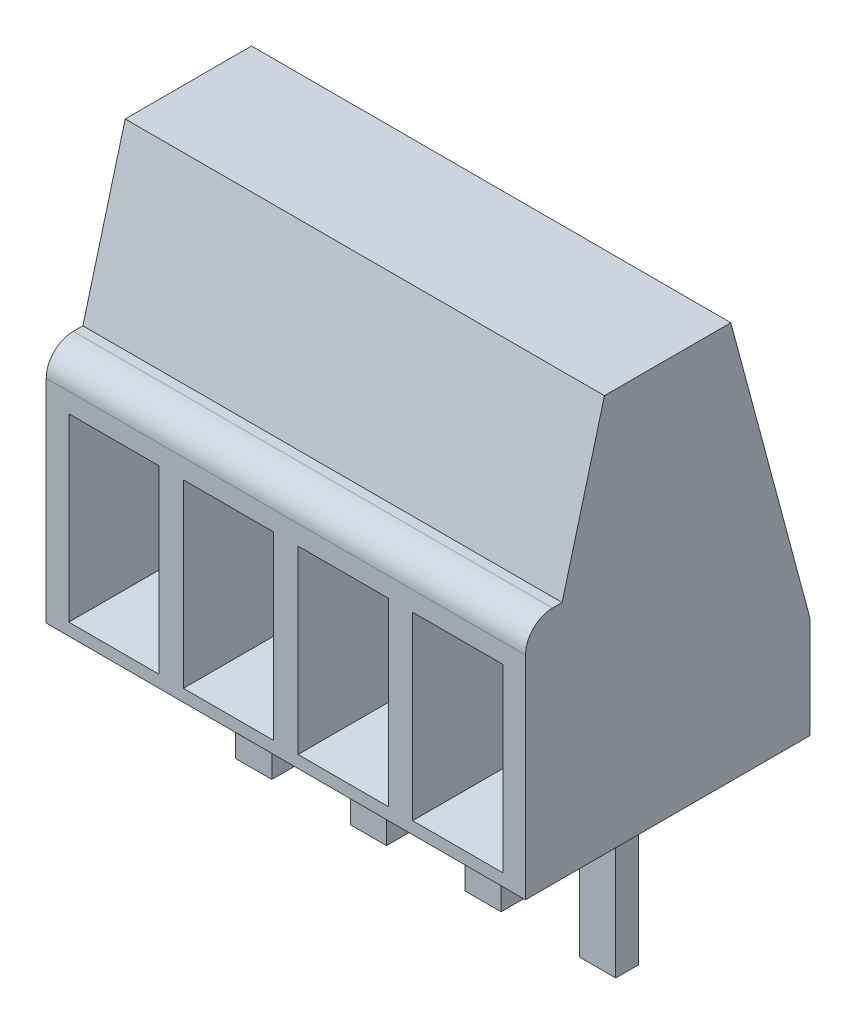
from build123d import *

# Parameters (mm, degrees)
SKETCH1_W           = 10.62
SKETCH1_H           = 6.3
BOSS_EXTRUDE1_DEPTH = 8.8
SKETCH2_W           = 0.8
SKETCH2_H           = 0.5
BOSS_EXTRUDE2_DEPTH = 3.6
CUT_EXTRUDE1_REACH  = 12.62
SKETCH4_W           = 2
SKETCH4_H           = 4
CUT_EXTRUDE2_DEPTH  = 3.15
CUT_EXTRUDE2_TAPER  = 10


with BuildPart() as part:
    # Sketch1 → Boss-Extrude1 (new body)
    with BuildSketch(Plane(origin=(0, 0, 0), x_dir=(1, 0, 0), z_dir=(0, 1, 0))):
        Rectangle(SKETCH1_W, SKETCH1_H)
    extrude(amount=BOSS_EXTRUDE1_DEPTH)

    # Sketch2 → Boss-Extrude2 (add)
    with BuildSketch(Plane(origin=(0, 0, 0), x_dir=(1, 0, 0), z_dir=(0, 1, 0))):
        with Locations((1.27, 0.2)):
            Rectangle(SKETCH2_W, SKETCH2_H)
        with Locations((3.81, 0.2)):
            Rectangle(SKETCH2_W, SKETCH2_H)
        with Locations((-1.27, 0.2)):
            Rectangle(SKETCH2_W, SKETCH2_H)
        with Locations((-3.81, 0.2)):
            Rectangle(SKETCH2_W, SKETCH2_H)
    extrude(amount=-BOSS_EXTRUDE2_DEPTH)

    # Sketch3 → Cut-Extrude1 (cut, up to next)
    with BuildSketch(Plane(origin=(5.31, 0, 0), x_dir=(0, 0, -1), z_dir=(1, 0, 0)), mode=Mode.PRIVATE) as cut_extrude1_sk1:
        with BuildLine():
            ThreePointArc((-3.15, 4.7), (-2.974264069, 5.124264069), (-2.55, 5.3))
            Line((-2.55, 5.3), (-2.337822174, 5.3))
            Line((-2.337822174, 5.3), (-1.4, 8.8))
            Line((-1.4, 8.8), (-3.15, 8.8))
            Line((-3.15, 8.8), (-3.15, 4.7))
        make_face()
    cut_extrude1_tool1 = extrude(cut_extrude1_sk1.sketch, amount=-CUT_EXTRUDE1_REACH, mode=Mode.PRIVATE) & part.part
    add(cut_extrude1_tool1.solids().sort_by_distance((5.31, 7.227986, 2.489914))[0], mode=Mode.SUBTRACT)
    # Sketch3 → Cut-Extrude1 (cut, up to next)
    with BuildSketch(Plane(origin=(5.31, 0, 0), x_dir=(0, 0, -1), z_dir=(1, 0, 0)), mode=Mode.PRIVATE) as cut_extrude1_sk2:
        Polygon((3.15, 8.8), (1.4, 8.8), (3.15, 2.268911087), align=None)
    cut_extrude1_tool2 = extrude(cut_extrude1_sk2.sketch, amount=-CUT_EXTRUDE1_REACH, mode=Mode.PRIVATE) & part.part
    add(cut_extrude1_tool2.solids().sort_by_distance((5.31, 6.62297, -2.566667))[0], mode=Mode.SUBTRACT)

    # Sketch4 → Cut-Extrude2 (cut)
    with BuildSketch(Plane.XY.offset(3.15)):
        with Locations((-3.81, 2.268911087)):
            Rectangle(SKETCH4_W, SKETCH4_H)
        with Locations((-1.27, 2.268911087)):
            Rectangle(SKETCH4_W, SKETCH4_H)
        with Locations((1.27, 2.268911087)):
            Rectangle(SKETCH4_W, SKETCH4_H)
        with Locations((3.81, 2.268911087)):
            Rectangle(SKETCH4_W, SKETCH4_H)
    extrude(amount=-CUT_EXTRUDE2_DEPTH, taper=CUT_EXTRUDE2_TAPER, mode=Mode.SUBTRACT)


solid = part.part
